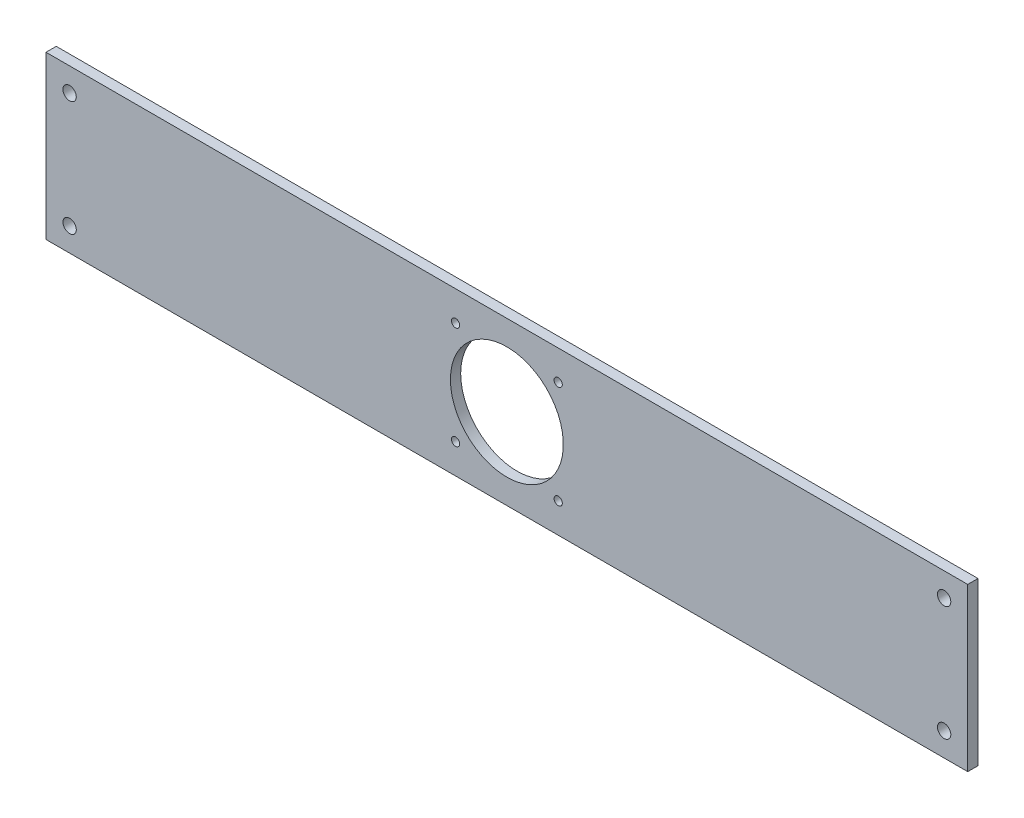
from build123d import *

# Parameters (mm, degrees)
SKETCH_F_W                   = 449
SKETCH_F_H                   = 79
SKETCH_F_R                   = 3.25
ESTRUSIONE_ESTRUSIONE1_DEPTH = 5
F_4_0_4_DIAMETER_HOLE1_D     = 4
SKETCH5_R                    = 27.5
CUT_EXTRUDE1_DEPTH           = 6


with BuildPart() as part:
    # f → Estrusione-Estrusione1 (new body)
    with BuildSketch(Plane.XY):
        with Locations((224.5, 39.5)):
            Rectangle(SKETCH_F_W, SKETCH_F_H)
        with Locations((11.5, 67.5)):
            Circle(SKETCH_F_R, mode=Mode.SUBTRACT)
        with Locations((437.5, 67.5)):
            Circle(SKETCH_F_R, mode=Mode.SUBTRACT)
        with Locations((11.5, 11.5)):
            Circle(SKETCH_F_R, mode=Mode.SUBTRACT)
        with Locations((437.5, 11.5)):
            Circle(SKETCH_F_R, mode=Mode.SUBTRACT)
    extrude(amount=ESTRUSIONE_ESTRUSIONE1_DEPTH)

    # Ø4.0 (4) Diameter Hole1 (through all)
    with Locations(Plane(origin=(0, 0, 0), x_dir=(-1, 0, 0), z_dir=(0, 0, -1))):
        with Locations((-249.5, 64.5), (-199.5, 64.5), (-249.5, 14.5), (-199.5, 14.5)):
            Hole(F_4_0_4_DIAMETER_HOLE1_D / 2)

    # Sketch5 → Cut-Extrude1 (cut, through all)
    with BuildSketch(Plane(origin=(0, 0, 0), x_dir=(-1, 0, 0), z_dir=(0, 0, -1))):
        with Locations((-224.5, 39.5)):
            Circle(SKETCH5_R)
    extrude(amount=-CUT_EXTRUDE1_DEPTH, mode=Mode.SUBTRACT)


solid = part.part
